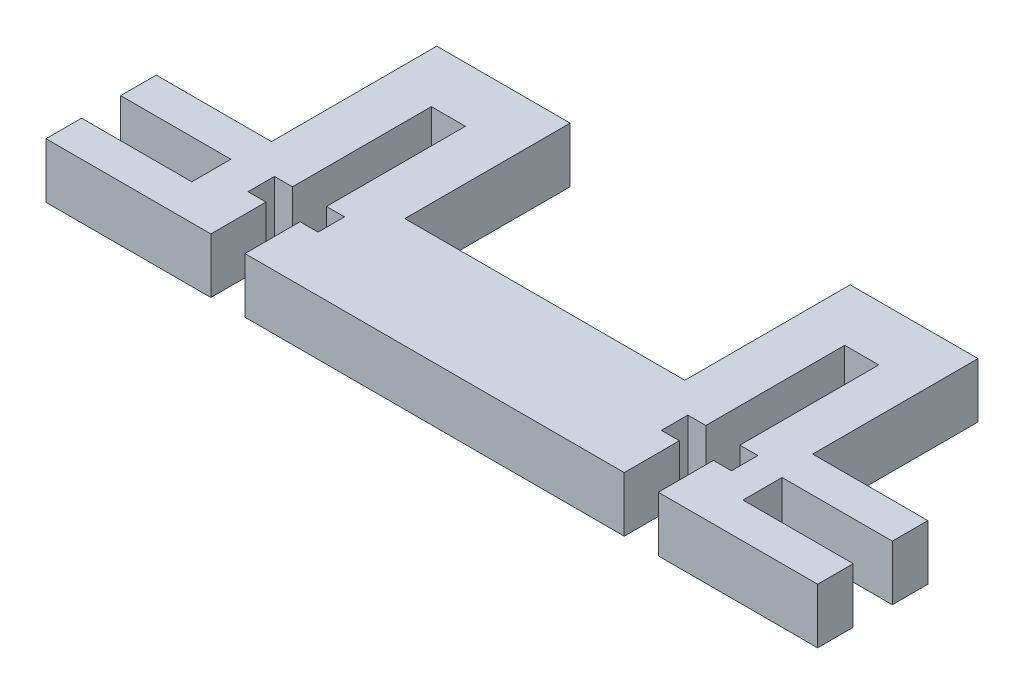
from build123d import *

# Parameters (mm, degrees)
SKETCH1_W           = 88.9
SKETCH1_H           = 12.7
BOSS_EXTRUDE1_DEPTH = 6.35
SKETCH2_W           = 14.725
SKETCH2_H           = 6.326510552
SKETCH2_W_2         = 15.361563021
SKETCH2_H_2         = 6.35
BOSS_EXTRUDE2_DEPTH = 19.05
CUT_EXTRUDE1_DEPTH  = 7.35
CUT_EXTRUDE2_DEPTH  = 7.35


with BuildPart() as part:
    # Sketch1 → Boss-Extrude1 (new body)
    with BuildSketch(Plane(origin=(0, 0, 0), x_dir=(1, 0, 0), z_dir=(0, 1, 0))):
        with Locations((44.45, -6.35)):
            Rectangle(SKETCH1_W, SKETCH1_H)
    extrude(amount=BOSS_EXTRUDE1_DEPTH)

    # Sketch2 → Boss-Extrude2 (add)
    with BuildSketch(Plane(origin=(0, 0, 0), x_dir=(-1, 0, 0), z_dir=(0, 0, -1))):
        with Locations((-68.2625, 3.186744724)):
            Rectangle(SKETCH2_W, SKETCH2_H)
        with Locations((-20.95578151, 3.175)):
            Rectangle(SKETCH2_W_2, SKETCH2_H_2)
    extrude(amount=BOSS_EXTRUDE2_DEPTH)

    # Sketch3 → Cut-Extrude1 (cut, through all)
    with BuildSketch(Plane(origin=(0, 6.35, 0), x_dir=(1, 0, 0), z_dir=(0, 1, 0))):
        Polygon((12.7, -6.35), (12.7, -4.1), (0, -4.1), (0, -8.6), (12.7, -8.6), align=None)
        Polygon((76.2, -6.35), (76.2, -4.1), (88.9, -4.1), (88.9, -8.6), (76.2, -8.6), align=None)
    extrude(amount=-CUT_EXTRUDE1_DEPTH, mode=Mode.SUBTRACT)

    # Sketch4 → Cut-Extrude2 (cut, through all)
    with BuildSketch(Plane(origin=(0, 6.35, 0), x_dir=(1, 0, 0), z_dir=(0, 1, 0))):
        Polygon((20.95578151, -12.7), (22.91828151, -12.7), (22.91828151, -6.35), (24.99328151, -6.35), (24.99328151, -3.302), (22.91828151, -3.302), (22.91828151, 12.7), (18.99328151, 12.7), (18.99328151, -3.302), (16.91828151, -3.302), (16.91828151, -6.35), (18.99328151, -6.35), (18.99328151, -12.7), align=None)
        Polygon((70.54328151, 12.7), (70.54328151, -3.302), (72.61828151, -3.302), (72.61828151, -6.35), (70.54328151, -6.35), (70.54328151, -12.7), (68.58078151, -12.7), (66.61828151, -12.7), (66.61828151, -6.35), (64.54328151, -6.35), (64.54328151, -3.302), (66.61828151, -3.302), (66.61828151, 12.7), align=None)
    extrude(amount=-CUT_EXTRUDE2_DEPTH, mode=Mode.SUBTRACT)


solid = part.part
